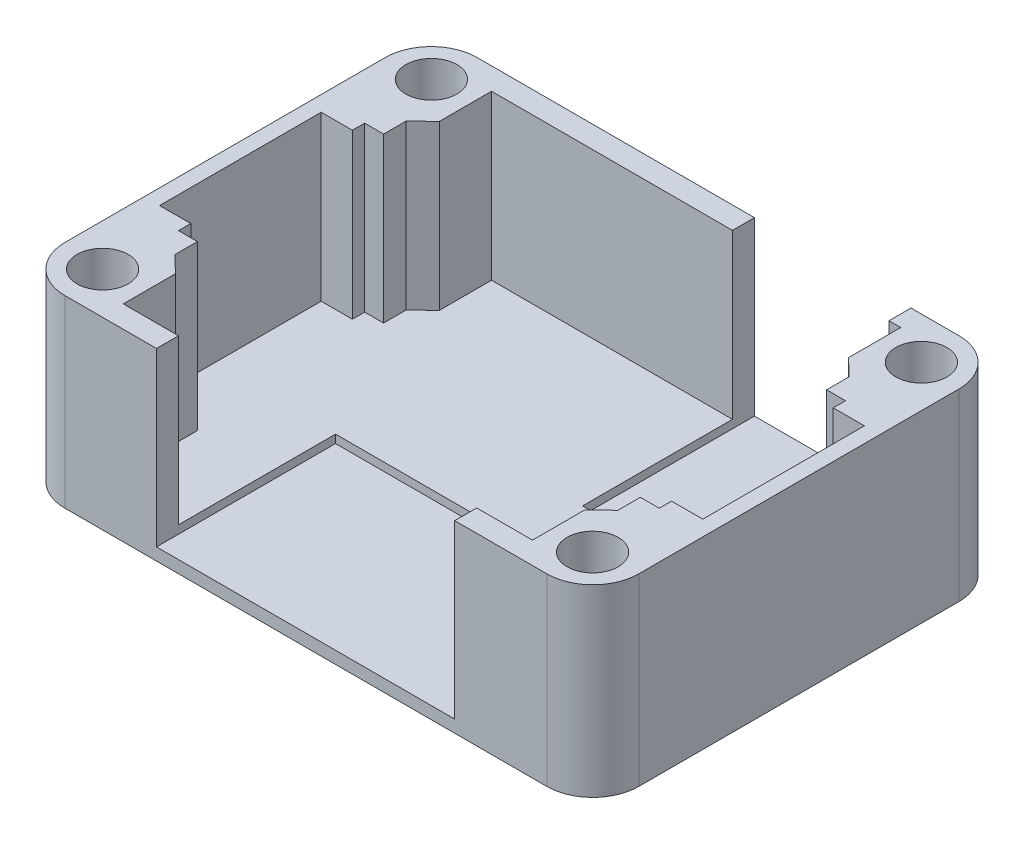
from build123d import *

# Parameters (mm, degrees)
BOSS_EXTRUDE1_DEPTH = 16
BOSS_EXTRUDE2_DEPTH = 2
SKETCH3_W           = 15.3
SKETCH3_H           = 16.8
CUT_EXTRUDE1_DEPTH  = 16.8
SKETCH4_R           = 2.5
CUT_EXTRUDE2_DEPTH  = 19
SKETCH5_W           = 29.15
SKETCH5_H           = 16.8
CUT_EXTRUDE3_DEPTH  = 17.5


with BuildPart() as part:
    # Sketch1 → Boss-Extrude1 (new body)
    with BuildSketch(Plane(origin=(0, 0, 0), x_dir=(1, 0, 0), z_dir=(0, 1, 0))):
        with BuildLine():
            Line((23.55, 20.15), (-23.55, 20.15))
            ThreePointArc((-23.55, 20.15), (-26.731980515, 18.831980515), (-28.05, 15.65))
            Line((-28.05, 15.65), (-28.05, -15.65))
            ThreePointArc((-28.05, -15.65), (-26.731980515, -18.831980515), (-23.55, -20.15))
            Line((-23.55, -20.15), (23.55, -20.15))
            ThreePointArc((23.55, -20.15), (26.731980515, -18.831980515), (28.05, -15.65))
            Line((28.05, -15.65), (28.05, 15.65))
            ThreePointArc((28.05, 15.65), (26.731980515, 18.831980515), (23.55, 20.15))
        make_face()
        Polygon((-20, -18), (20, -18), (20, -12.9), (21.65, -11.3), (21.65, -9.1), (23.5, -9.1), (23.5, -7.9), (26.55, -7.9), (26.55, 7.9), (23.5, 7.9), (23.5, 9.1), (21.65, 9.1), (21.65, 11.3), (20, 12.9), (20, 18), (-20, 18), (-20, 12.9), (-21.65, 11.3), (-21.65, 9.1), (-23.5, 9.1), (-23.5, 7.9), (-26.55, 7.9), (-26.55, -7.9), (-23.5, -7.9), (-23.5, -9.1), (-21.65, -9.1), (-21.65, -11.3), (-20, -12.9), align=None, mode=Mode.SUBTRACT)
    extrude(amount=BOSS_EXTRUDE1_DEPTH)

    # Sketch2 → Boss-Extrude2 (add)
    with BuildSketch(Plane.XZ):
        with BuildLine():
            Line((-23.55, -20.15), (23.55, -20.15))
            ThreePointArc((23.55, -20.15), (26.731980515, -18.831980515), (28.05, -15.65))
            Line((28.05, -15.65), (28.05, 15.65))
            ThreePointArc((28.05, 15.65), (26.731980515, 18.831980515), (23.55, 20.15))
            Line((23.55, 20.15), (-23.55, 20.15))
            ThreePointArc((-23.55, 20.15), (-26.731980515, 18.831980515), (-28.05, 15.65))
            Line((-28.05, 15.65), (-28.05, -15.65))
            ThreePointArc((-28.05, -15.65), (-26.731980515, -18.831980515), (-23.55, -20.15))
        make_face()
    extrude(amount=BOSS_EXTRUDE2_DEPTH)

    # Sketch3 → Cut-Extrude1 (cut)
    with BuildSketch(Plane(origin=(0, 0, -20.15), x_dir=(-1, 0, 0), z_dir=(0, 0, -1))):
        with Locations((-11.2, 7.6)):
            Rectangle(SKETCH3_W, SKETCH3_H)
    extrude(amount=-CUT_EXTRUDE1_DEPTH, mode=Mode.SUBTRACT)

    # Sketch4 → Cut-Extrude2 (cut, through all)
    with BuildSketch(Plane(origin=(0, 16, 0), x_dir=(1, 0, 0), z_dir=(0, 1, 0))):
        with Locations((23.95, 16.069558847)):
            Circle(SKETCH4_R)
        with Locations((23.95, -16.069558847)):
            Circle(SKETCH4_R)
        with Locations((-23.95, 16.069558847)):
            Circle(SKETCH4_R)
        with Locations((-23.95, -16.069558847)):
            Circle(SKETCH4_R)
    extrude(amount=-CUT_EXTRUDE2_DEPTH, mode=Mode.SUBTRACT)

    # Sketch5 → Cut-Extrude3 (cut)
    with BuildSketch(Plane.XY.offset(20.15)):
        with Locations((-0.025, 7.6)):
            Rectangle(SKETCH5_W, SKETCH5_H)
    extrude(amount=-CUT_EXTRUDE3_DEPTH, mode=Mode.SUBTRACT)


solid = part.part
